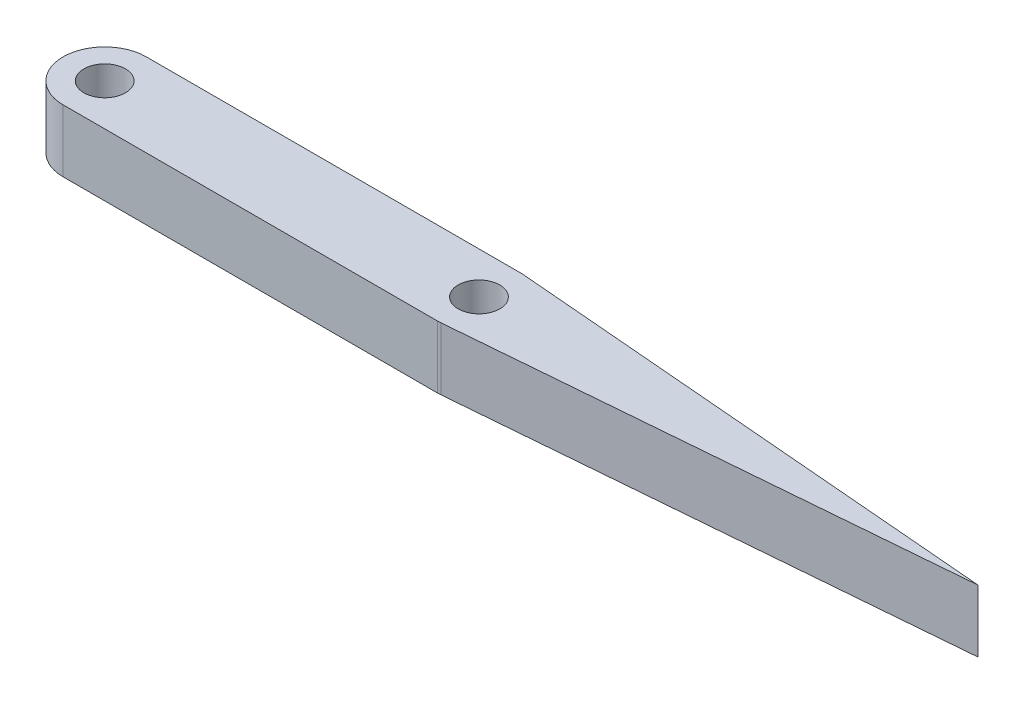
from build123d import *

# Parameters (mm, degrees)
SKETCH_1_R      = 1
EXTRUDE_1_DEPTH = 3


with BuildPart() as part:
    # 草图1 → 凸台-拉伸1 (new body)
    with BuildSketch(Plane(origin=(0, 0, 0), x_dir=(1, 0, 0), z_dir=(0, 1, 0))):
        with BuildLine():
            Line((0, 2), (18, 2))
            ThreePointArc((18, 2), (18.083405892, 1.998260107), (18.166666667, 1.993043457))
            Line((18.166666667, 1.993043457), (42, 0))
            Line((42, 0), (18.166666667, -1.993043457))
            ThreePointArc((18.166666667, -1.993043457), (18.083405892, -1.998260107), (18, -2))
            Line((18, -2), (0, -2))
            ThreePointArc((0, -2), (-2, 0), (0, 2))
        make_face()
        Circle(SKETCH_1_R, mode=Mode.SUBTRACT)
        with Locations((18, 0)):
            Circle(SKETCH_1_R, mode=Mode.SUBTRACT)
    extrude(amount=EXTRUDE_1_DEPTH)


solid = part.part
